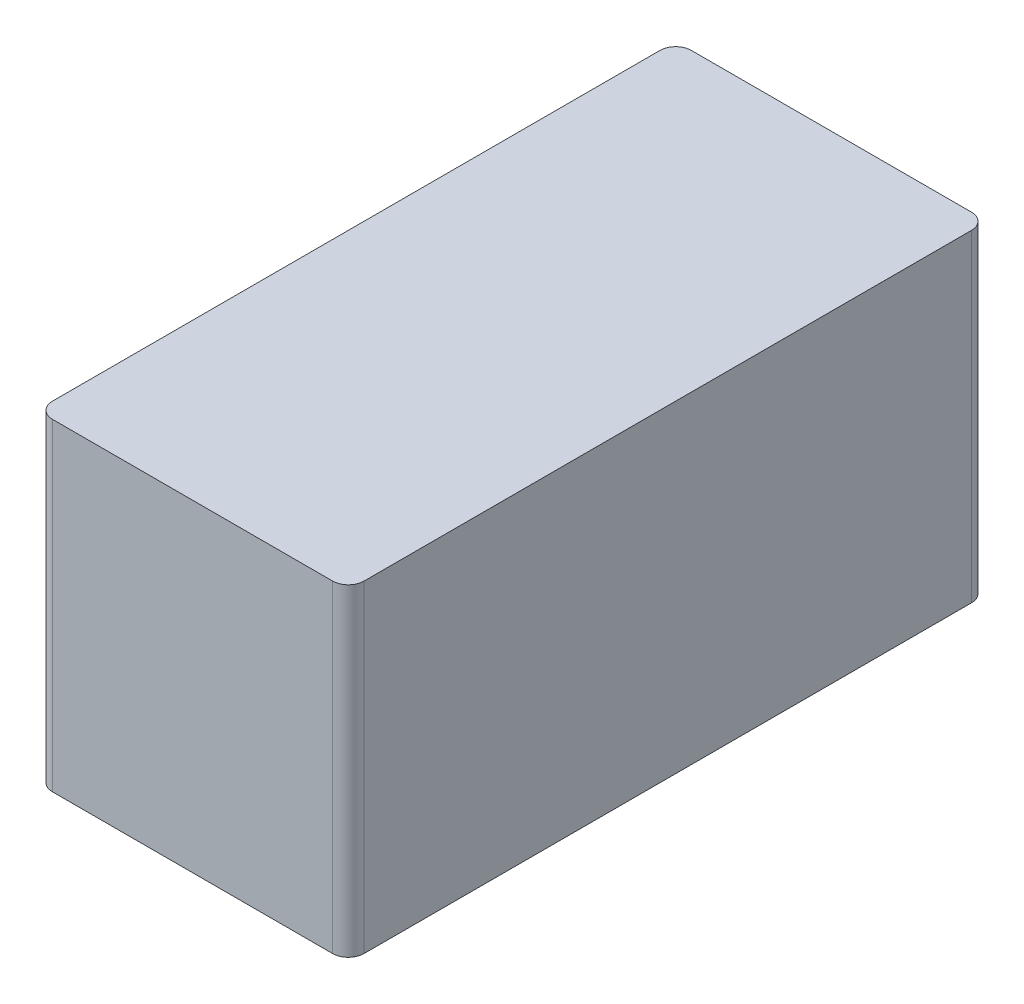
from build123d import *

# Parameters (mm, degrees)
SKETCH1_W           = 19.8
SKETCH1_H           = 40.6
BOSS_EXTRUDE1_DEPTH = 10.25
FILLET1_R           = 1


with BuildPart() as part:
    # Sketch1 → Boss-Extrude1 (new body, symmetric)
    with BuildSketch(Plane(origin=(0, 0, 0), x_dir=(1, 0, 0), z_dir=(0, 1, 0))):
        Rectangle(SKETCH1_W, SKETCH1_H)
    extrude(amount=BOSS_EXTRUDE1_DEPTH, both=True)

    # Fillet1
    fillet1_edges = [part.edges().sort_by_distance(p)[0] for p in [
        (9.9, 0, 20.3),
        (-9.9, 0, 20.3),
        (-9.9, 0, -20.3),
        (9.9, 0, -20.3),
    ]]
    fillet(fillet1_edges, radius=FILLET1_R)


solid = part.part
